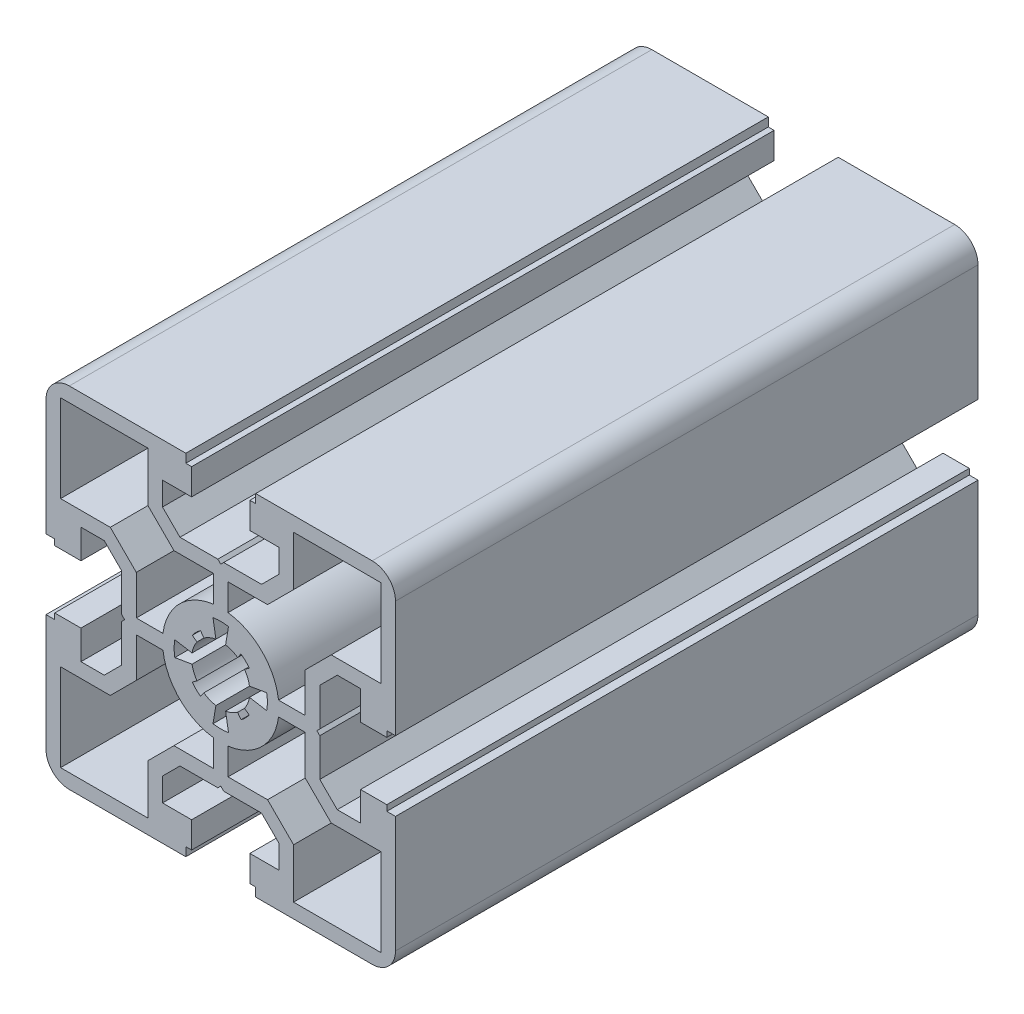
from build123d import *

# Parameters (mm, degrees)
Y_KSEKLIK_EKSTR_ZYON1_DEPTH = 100


with BuildPart() as part:
    # Çizim1 → Yükseklik-Ekstrüzyon1 (new body)
    with BuildSketch(Plane.XY.offset(100)):
        with BuildLine():
            Line((6, -28.5), (6, -30))
            Line((6, -30), (26, -30))
            ThreePointArc((26, -30), (28.828427125, -28.828427125), (30, -26))
            Line((30, -26), (30, -6))
            Line((30, -6), (28.5, -6))
            Line((28.5, -6), (28.5, -5))
            Line((28.5, -5), (24, -5))
            Line((24, -5), (24, -10))
            Line((24, -10), (20, -10))
            Line((20, -10), (17, -7))
            Line((17, -7), (17, -0.5))
            Line((17, -0.5), (16.5, 0))
            Line((16.5, 0), (17, 0.5))
            Line((17, 0.5), (17, 7))
            Line((17, 7), (20, 10))
            Line((20, 10), (24, 10))
            Line((24, 10), (24, 5))
            Line((24, 5), (28.5, 5))
            Line((28.5, 5), (28.5, 6))
            Line((28.5, 6), (30, 6))
            Line((30, 6), (30, 26))
            ThreePointArc((30, 26), (28.828427125, 28.828427125), (26, 30))
            Line((26, 30), (6, 30))
            Line((6, 30), (6, 28.5))
            Line((6, 28.5), (5, 28.5))
            Line((5, 28.5), (5, 24))
            Line((5, 24), (10, 24))
            Line((10, 24), (10, 20))
            Line((10, 20), (7, 17))
            Line((7, 17), (0.5, 17))
            Line((0.5, 17), (0, 16.5))
            Line((0, 16.5), (-0.5, 17))
            Line((-0.5, 17), (-7, 17))
            Line((-7, 17), (-10, 20))
            Line((-10, 20), (-10, 24))
            Line((-10, 24), (-5, 24))
            Line((-5, 24), (-5, 28.5))
            Line((-5, 28.5), (-6, 28.5))
            Line((-6, 28.5), (-6, 30))
            Line((-6, 30), (-26, 30))
            ThreePointArc((-26, 30), (-28.828427125, 28.828427125), (-30, 26))
            Line((-30, 26), (-30, 6))
            Line((-30, 6), (-28.5, 6))
            Line((-28.5, 6), (-28.5, 5))
            Line((-28.5, 5), (-24, 5))
            Line((-24, 5), (-24, 10))
            Line((-24, 10), (-20, 10))
            Line((-20, 10), (-17, 7))
            Line((-17, 7), (-17, 0.5))
            Line((-17, 0.5), (-16.5, 0))
            Line((-16.5, 0), (-17, -0.5))
            Line((-17, -0.5), (-17, -7))
            Line((-17, -7), (-20, -10))
            Line((-20, -10), (-24, -10))
            Line((-24, -10), (-24, -5))
            Line((-24, -5), (-28.5, -5))
            Line((-28.5, -5), (-28.5, -6))
            Line((-28.5, -6), (-30, -6))
            Line((-30, -6), (-30, -26))
            ThreePointArc((-30, -26), (-28.828427125, -28.828427125), (-26, -30))
            Line((-26, -30), (-6, -30))
            Line((-6, -30), (-6, -28.5))
            Line((-6, -28.5), (-5, -28.5))
            Line((-5, -28.5), (-5, -24))
            Line((-5, -24), (-10, -24))
            Line((-10, -24), (-10, -20))
            Line((-10, -20), (-7, -17))
            Line((-7, -17), (-0.5, -17))
            Line((-0.5, -17), (0, -16.5))
            Line((0, -16.5), (0.5, -17))
            Line((0.5, -17), (7, -17))
            Line((7, -17), (10, -20))
            Line((10, -20), (10, -24))
            Line((10, -24), (5, -24))
            Line((5, -24), (5, -28.5))
            Line((5, -28.5), (6, -28.5))
        make_face()
        with BuildLine():
            Line((0.832983278, -4.930125652), (1.332773242, -7.88820103))
            ThreePointArc((1.332773242, -7.88820103), (1e-09, -8), (-1.33277324, -7.88820103))
            Line((-1.33277324, -7.88820103), (-0.832983276, -4.930125653))
            ThreePointArc((-0.832983276, -4.930125653), (-1.913417159, -4.619397673), (-2.897117147, -4.075133412))
            Line((-2.897117147, -4.075133412), (-3.476540579, -4.890160098))
            ThreePointArc((-3.476540579, -4.890160098), (-4.242640692, -4.242640704), (-4.890160088, -3.476540593))
            Line((-4.890160088, -3.476540593), (-4.075133404, -2.897117158))
            ThreePointArc((-4.075133404, -2.897117158), (-4.619397678, -1.913417147), (-4.930125659, -0.832983237))
            Line((-4.930125659, -0.832983237), (-7.888201041, -1.332773176))
            ThreePointArc((-7.888201041, -1.332773176), (-8, 3.5e-08), (-7.888201029, 1.332773245))
            Line((-7.888201029, 1.332773245), (-4.930125652, 0.83298328))
            ThreePointArc((-4.930125652, 0.83298328), (-4.619397673, 1.913417161), (-4.075133412, 2.897117148))
            Line((-4.075133412, 2.897117148), (-4.890160097, 3.47654058))
            ThreePointArc((-4.890160097, 3.47654058), (-4.242640703, 4.242640692), (-3.476540592, 4.890160089))
            Line((-3.476540592, 4.890160089), (-2.897117158, 4.075133404))
            ThreePointArc((-2.897117158, 4.075133404), (-1.913417166, 4.619397671), (-0.832983278, 4.930125652))
            Line((-0.832983278, 4.930125652), (-1.332773242, 7.88820103))
            ThreePointArc((-1.332773242, 7.88820103), (-1e-09, 8), (1.33277324, 7.88820103))
            Line((1.33277324, 7.88820103), (0.832983276, 4.930125653))
            ThreePointArc((0.832983276, 4.930125653), (1.913417166, 4.619397671), (2.897117158, 4.075133404))
            Line((2.897117158, 4.075133404), (3.476540592, 4.890160088))
            ThreePointArc((3.476540592, 4.890160088), (4.242640703, 4.242640692), (4.890160098, 3.476540579))
            Line((4.890160098, 3.476540579), (4.075133412, 2.897117147))
            ThreePointArc((4.075133412, 2.897117147), (4.619397681, 1.913417141), (4.930125659, 0.832983237))
            Line((4.930125659, 0.832983237), (7.888201041, 1.332773176))
            ThreePointArc((7.888201041, 1.332773176), (8, -3.5e-08), (7.88820103, -1.332773245))
            Line((7.88820103, -1.332773245), (4.930125652, -0.83298328))
            ThreePointArc((4.930125652, -0.83298328), (4.61939767, -1.913417167), (4.075133404, -2.897117159))
            Line((4.075133404, -2.897117159), (4.890160088, -3.476540593))
            ThreePointArc((4.890160088, -3.476540593), (4.242640698, -4.242640697), (3.476540594, -4.890160088))
            Line((3.476540594, -4.890160088), (2.897117159, -4.075133403))
            ThreePointArc((2.897117159, -4.075133403), (1.913417167, -4.61939767), (0.832983278, -4.930125652))
        make_face(mode=Mode.SUBTRACT)
        with BuildLine():
            Line((12.5, 18.964466094), (12.5, 27.5))
            Line((12.5, 27.5), (27.5, 27.5))
            Line((27.5, 27.5), (27.5, 12.5))
            Line((27.5, 12.5), (18.964466094, 12.5))
            Line((18.964466094, 12.5), (14.5, 8.035533906))
            Line((14.5, 8.035533906), (14.5, 1.250000001))
            Line((14.5, 1.250000001), (9.921567416, 1.250000001))
            ThreePointArc((9.921567416, 1.250000001), (7.071067812, 7.071067812), (1.250000001, 9.921567416))
            Line((1.250000001, 9.921567416), (1.250000001, 14.5))
            Line((1.250000001, 14.5), (8.035533906, 14.5))
            Line((8.035533906, 14.5), (12.5, 18.964466094))
        make_face(mode=Mode.SUBTRACT)
        with BuildLine():
            Line((18.964466094, -12.5), (27.5, -12.5))
            Line((27.5, -12.5), (27.5, -27.5))
            Line((27.5, -27.5), (12.5, -27.5))
            Line((12.5, -27.5), (12.5, -18.964466094))
            Line((12.5, -18.964466094), (8.035533906, -14.5))
            Line((8.035533906, -14.5), (1.250000001, -14.5))
            Line((1.250000001, -14.5), (1.250000001, -9.921567416))
            ThreePointArc((1.250000001, -9.921567416), (7.071067812, -7.071067812), (9.921567416, -1.250000001))
            Line((9.921567416, -1.250000001), (14.5, -1.250000001))
            Line((14.5, -1.250000001), (14.5, -8.035533906))
            Line((14.5, -8.035533906), (18.964466094, -12.5))
        make_face(mode=Mode.SUBTRACT)
        with BuildLine():
            Line((-12.5, -18.964466094), (-12.5, -27.5))
            Line((-12.5, -27.5), (-27.5, -27.5))
            Line((-27.5, -27.5), (-27.5, -12.5))
            Line((-27.5, -12.5), (-18.964466094, -12.5))
            Line((-18.964466094, -12.5), (-14.5, -8.035533906))
            Line((-14.5, -8.035533906), (-14.5, -1.250000001))
            Line((-14.5, -1.250000001), (-9.921567416, -1.250000001))
            ThreePointArc((-9.921567416, -1.250000001), (-7.071067812, -7.071067812), (-1.250000001, -9.921567416))
            Line((-1.250000001, -9.921567416), (-1.250000001, -14.5))
            Line((-1.250000001, -14.5), (-8.035533906, -14.5))
            Line((-8.035533906, -14.5), (-12.5, -18.964466094))
        make_face(mode=Mode.SUBTRACT)
        with BuildLine():
            Line((-18.964466094, 12.5), (-27.5, 12.5))
            Line((-27.5, 12.5), (-27.5, 27.5))
            Line((-27.5, 27.5), (-12.5, 27.5))
            Line((-12.5, 27.5), (-12.5, 18.964466094))
            Line((-12.5, 18.964466094), (-8.035533906, 14.5))
            Line((-8.035533906, 14.5), (-1.250000001, 14.5))
            Line((-1.250000001, 14.5), (-1.250000001, 9.921567416))
            ThreePointArc((-1.250000001, 9.921567416), (-7.071067812, 7.071067812), (-9.921567416, 1.250000001))
            Line((-9.921567416, 1.250000001), (-14.5, 1.250000001))
            Line((-14.5, 1.250000001), (-14.5, 8.035533906))
            Line((-14.5, 8.035533906), (-18.964466094, 12.5))
        make_face(mode=Mode.SUBTRACT)
    extrude(amount=-Y_KSEKLIK_EKSTR_ZYON1_DEPTH)


solid = part.part
